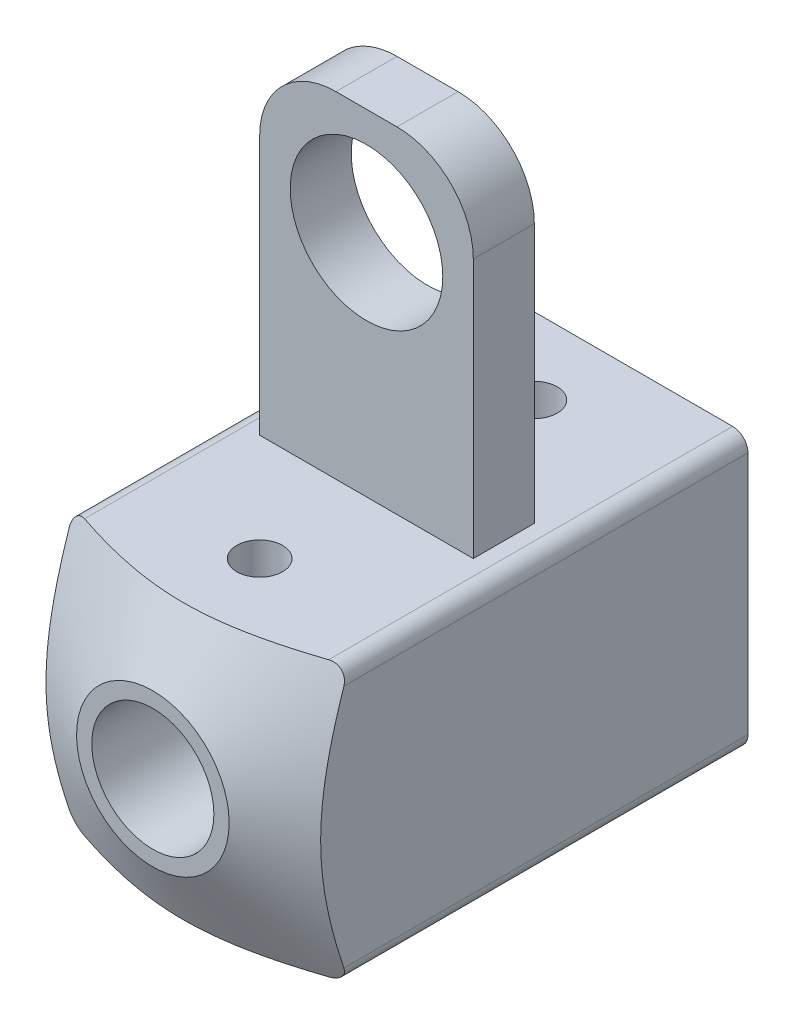
from build123d import *

# Parameters (mm, degrees)
SKETCH1_W           = 18
SKETCH1_H           = 18
BOSS_EXTRUDE1_DEPTH = 30
FILLET1_R           = 1
SKETCH3_R           = 4
CUT_EXTRUDE1_DEPTH  = 10
SKETCH4_R           = 6
CUT_EXTRUDE2_DEPTH  = 10
SKETCH5_R           = 1.5
CUT_EXTRUDE3_DEPTH  = 19.0000001
SKETCH7_R           = 5
BOSS_EXTRUDE2_DEPTH = 4


with BuildPart() as part:
    # Sketch1 → Boss-Extrude1 (new body)
    with BuildSketch(Plane.XY):
        Rectangle(SKETCH1_W, SKETCH1_H)
    extrude(amount=-BOSS_EXTRUDE1_DEPTH)

    # Sketch2 → Cut-Revolve1 (revolve, cut)
    with BuildSketch(Plane(origin=(0, 0, 0), x_dir=(0, 0, -1), z_dir=(1, 0, 0))):
        Polygon((0, 5), (0, 12.689629666), (3.844814833, 12.689629666), align=None)
    revolve(axis=Axis((0, 0, 0), (0, 0, -1)), mode=Mode.SUBTRACT)

    # Fillet1
    fillet1_edges = [part.edges().sort_by_distance(p)[0] for p in [
        (9, -9, -15),
        (-9, -9, -15),
        (-9, 9, -15),
        (9, 9, -15),
    ]]
    fillet(fillet1_edges, radius=FILLET1_R)

    # Sketch3 → Cut-Extrude1 (cut)
    with BuildSketch(Plane.XY):
        Circle(SKETCH3_R)
    extrude(amount=-CUT_EXTRUDE1_DEPTH, mode=Mode.SUBTRACT)

    # Sketch4 → Cut-Extrude2 (cut)
    with BuildSketch(Plane(origin=(0, 0, -30), x_dir=(-1, 0, 0), z_dir=(0, 0, -1))):
        Circle(SKETCH4_R)
    extrude(amount=-CUT_EXTRUDE2_DEPTH, mode=Mode.SUBTRACT)

    # Sketch5 → Cut-Extrude3 (cut, through all)
    with BuildSketch(Plane(origin=(0, 9, 0), x_dir=(1, 0, 0), z_dir=(0, 1, 0))):
        with Locations((0, 7)):
            Circle(SKETCH5_R)
        with Locations((0, 25)):
            Circle(SKETCH5_R)
    extrude(amount=-CUT_EXTRUDE3_DEPTH, mode=Mode.SUBTRACT)

    # Sketch7 → Boss-Extrude2 (add)
    with BuildSketch(Plane.XY.offset(-14)):
        with BuildLine():
            Line((-7, 9), (7, 9))
            Line((7, 9), (7, 26))
            ThreePointArc((7, 26), (5.535533906, 29.535533906), (2, 31))
            Line((2, 31), (-2, 31))
            ThreePointArc((-2, 31), (-5.535533906, 29.535533906), (-7, 26))
            Line((-7, 26), (-7, 9))
        make_face()
        with Locations((0, 24)):
            Circle(SKETCH7_R, mode=Mode.SUBTRACT)
    extrude(amount=-BOSS_EXTRUDE2_DEPTH)


solid = part.part
